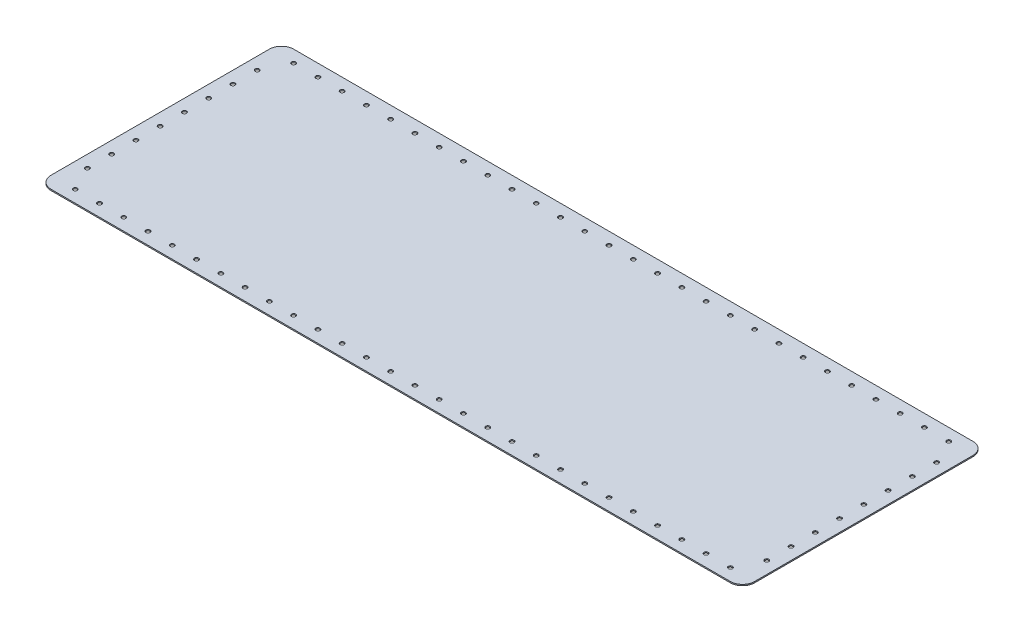
from build123d import *

# Parameters (mm, degrees)
SKETCH1_W                      = 580
SKETCH1_H                      = 200
BOSS_EXTRUDE1_DEPTH            = 1
FILLET1_R                      = 10
M3_CLEARANCE_HOLE1_AT_2_COUNT  = 2
M3_CLEARANCE_HOLE1_AT_2_PITCH  = 22.360679775
M3_CLEARANCE_HOLE1_AT_3_COUNT  = 2
M3_CLEARANCE_HOLE1_AT_3_PITCH  = 36.055512755
M3_CLEARANCE_HOLE1_AT_4_COUNT  = 2
M3_CLEARANCE_HOLE1_AT_4_PITCH  = 53.851648071
M3_CLEARANCE_HOLE1_AT_5_COUNT  = 2
M3_CLEARANCE_HOLE1_AT_5_PITCH  = 72.801098893
M3_CLEARANCE_HOLE1_AT_6_COUNT  = 2
M3_CLEARANCE_HOLE1_AT_6_PITCH  = 92.195444573
M3_CLEARANCE_HOLE1_AT_7_COUNT  = 2
M3_CLEARANCE_HOLE1_AT_7_PITCH  = 111.803398875
M3_CLEARANCE_HOLE1_AT_8_COUNT  = 2
M3_CLEARANCE_HOLE1_AT_8_PITCH  = 131.52946438
M3_CLEARANCE_HOLE1_AT_9_COUNT  = 2
M3_CLEARANCE_HOLE1_AT_9_PITCH  = 151.327459504
M3_CLEARANCE_HOLE1_AT_10_COUNT = 2
M3_CLEARANCE_HOLE1_AT_10_PITCH = 171.172427686
M3_CLEARANCE_HOLE1_AT_11_COUNT = 2
M3_CLEARANCE_HOLE1_AT_11_PITCH = 191.049731745
M3_CLEARANCE_HOLE1_AT_12_COUNT = 2
M3_CLEARANCE_HOLE1_AT_12_PITCH = 210.950231097
M3_CLEARANCE_HOLE1_AT_13_COUNT = 2
M3_CLEARANCE_HOLE1_AT_13_PITCH = 230.867927612
M3_CLEARANCE_HOLE1_AT_14_COUNT = 2
M3_CLEARANCE_HOLE1_AT_14_PITCH = 250.79872408
M3_CLEARANCE_HOLE1_AT_15_COUNT = 2
M3_CLEARANCE_HOLE1_AT_15_PITCH = 270.739727414
M3_CLEARANCE_HOLE1_AT_16_COUNT = 2
M3_CLEARANCE_HOLE1_AT_16_PITCH = 290.688837075
M3_CLEARANCE_HOLE1_AT_17_COUNT = 2
M3_CLEARANCE_HOLE1_AT_17_PITCH = 310.64449134
M3_CLEARANCE_HOLE1_AT_18_COUNT = 2
M3_CLEARANCE_HOLE1_AT_18_PITCH = 330.605505096
M3_CLEARANCE_HOLE1_AT_19_COUNT = 2
M3_CLEARANCE_HOLE1_AT_19_PITCH = 350.570962859
M3_CLEARANCE_HOLE1_AT_20_COUNT = 2
M3_CLEARANCE_HOLE1_AT_20_PITCH = 370.540146273
M3_CLEARANCE_HOLE1_AT_21_COUNT = 2
M3_CLEARANCE_HOLE1_AT_21_PITCH = 390.512483795
M3_CLEARANCE_HOLE1_AT_22_COUNT = 2
M3_CLEARANCE_HOLE1_AT_22_PITCH = 410.487515035
M3_CLEARANCE_HOLE1_AT_23_COUNT = 2
M3_CLEARANCE_HOLE1_AT_23_PITCH = 430.464865001
M3_CLEARANCE_HOLE1_AT_24_COUNT = 2
M3_CLEARANCE_HOLE1_AT_24_PITCH = 450.444225182
M3_CLEARANCE_HOLE1_AT_25_COUNT = 2
M3_CLEARANCE_HOLE1_AT_25_PITCH = 470.425339454
M3_CLEARANCE_HOLE1_AT_26_COUNT = 2
M3_CLEARANCE_HOLE1_AT_26_PITCH = 490.40799341
M3_CLEARANCE_HOLE1_AT_27_COUNT = 2
M3_CLEARANCE_HOLE1_AT_27_PITCH = 510.392006207
M3_CLEARANCE_HOLE1_AT_28_COUNT = 2
M3_CLEARANCE_HOLE1_AT_28_PITCH = 530.377224247
M3_CLEARANCE_HOLE1_AT_29_COUNT = 2
M3_CLEARANCE_HOLE1_AT_29_PITCH = 550.363516233
M3_CLEARANCE_HOLE1_AT_30_COUNT = 2
M3_CLEARANCE_HOLE1_AT_30_PITCH = 19.996953903
M3_CLEARANCE_HOLE1_AT_31_COUNT = 2
M3_CLEARANCE_HOLE1_AT_31_PITCH = 39.993907806
M3_CLEARANCE_HOLE1_AT_32_COUNT = 2
M3_CLEARANCE_HOLE1_AT_32_PITCH = 59.990861709
M3_CLEARANCE_HOLE1_AT_33_COUNT = 2
M3_CLEARANCE_HOLE1_AT_33_PITCH = 79.987815613
M3_CLEARANCE_HOLE1_AT_34_COUNT = 2
M3_CLEARANCE_HOLE1_AT_34_PITCH = 99.984769516
M3_CLEARANCE_HOLE1_AT_35_COUNT = 2
M3_CLEARANCE_HOLE1_AT_35_PITCH = 119.981723419
M3_CLEARANCE_HOLE1_AT_36_COUNT = 2
M3_CLEARANCE_HOLE1_AT_36_PITCH = 139.978677322
M3_CLEARANCE_HOLE1_AT_37_COUNT = 2
M3_CLEARANCE_HOLE1_AT_37_PITCH = 160.312195419
M3_CLEARANCE_HOLE1_AT_38_COUNT = 2
M3_CLEARANCE_HOLE1_AT_38_PITCH = 162.788205961
M3_CLEARANCE_HOLE1_AT_39_COUNT = 2
M3_CLEARANCE_HOLE1_AT_39_PITCH = 167.630546142
M3_CLEARANCE_HOLE1_AT_40_COUNT = 2
M3_CLEARANCE_HOLE1_AT_40_PITCH = 174.642491966
M3_CLEARANCE_HOLE1_AT_41_COUNT = 2
M3_CLEARANCE_HOLE1_AT_41_PITCH = 183.575597507
M3_CLEARANCE_HOLE1_AT_42_COUNT = 2
M3_CLEARANCE_HOLE1_AT_42_PITCH = 194.164878389
M3_CLEARANCE_HOLE1_AT_43_COUNT = 2
M3_CLEARANCE_HOLE1_AT_43_PITCH = 206.155281281
M3_CLEARANCE_HOLE1_AT_44_COUNT = 2
M3_CLEARANCE_HOLE1_AT_44_PITCH = 219.317121995
M3_CLEARANCE_HOLE1_AT_45_COUNT = 2
M3_CLEARANCE_HOLE1_AT_45_PITCH = 233.452350599
M3_CLEARANCE_HOLE1_AT_46_COUNT = 2
M3_CLEARANCE_HOLE1_AT_46_PITCH = 248.394846967
M3_CLEARANCE_HOLE1_AT_47_COUNT = 2
M3_CLEARANCE_HOLE1_AT_47_PITCH = 264.007575649
M3_CLEARANCE_HOLE1_AT_48_COUNT = 2
M3_CLEARANCE_HOLE1_AT_48_PITCH = 280.178514522
M3_CLEARANCE_HOLE1_AT_49_COUNT = 2
M3_CLEARANCE_HOLE1_AT_49_PITCH = 296.816441593
M3_CLEARANCE_HOLE1_AT_50_COUNT = 2
M3_CLEARANCE_HOLE1_AT_50_PITCH = 313.84709653
M3_CLEARANCE_HOLE1_AT_51_COUNT = 2
M3_CLEARANCE_HOLE1_AT_51_PITCH = 331.209903234
M3_CLEARANCE_HOLE1_AT_52_COUNT = 2
M3_CLEARANCE_HOLE1_AT_52_PITCH = 348.85527085
M3_CLEARANCE_HOLE1_AT_53_COUNT = 2
M3_CLEARANCE_HOLE1_AT_53_PITCH = 366.742416418
M3_CLEARANCE_HOLE1_AT_54_COUNT = 2
M3_CLEARANCE_HOLE1_AT_54_PITCH = 384.837628098
M3_CLEARANCE_HOLE1_AT_55_COUNT = 2
M3_CLEARANCE_HOLE1_AT_55_PITCH = 403.112887415
M3_CLEARANCE_HOLE1_AT_56_COUNT = 2
M3_CLEARANCE_HOLE1_AT_56_PITCH = 421.544778167
M3_CLEARANCE_HOLE1_AT_57_COUNT = 2
M3_CLEARANCE_HOLE1_AT_57_PITCH = 440.113621693
M3_CLEARANCE_HOLE1_AT_58_COUNT = 2
M3_CLEARANCE_HOLE1_AT_58_PITCH = 458.802789878
M3_CLEARANCE_HOLE1_AT_59_COUNT = 2
M3_CLEARANCE_HOLE1_AT_59_PITCH = 477.59815745
M3_CLEARANCE_HOLE1_AT_60_COUNT = 2
M3_CLEARANCE_HOLE1_AT_60_PITCH = 496.487663492
M3_CLEARANCE_HOLE1_AT_61_COUNT = 2
M3_CLEARANCE_HOLE1_AT_61_PITCH = 515.460958754
M3_CLEARANCE_HOLE1_AT_62_COUNT = 2
M3_CLEARANCE_HOLE1_AT_62_PITCH = 534.509120596
M3_CLEARANCE_HOLE1_AT_63_COUNT = 2
M3_CLEARANCE_HOLE1_AT_63_PITCH = 553.624421427
M3_CLEARANCE_HOLE1_AT_64_COUNT = 2
M3_CLEARANCE_HOLE1_AT_64_PITCH = 572.800139665
M3_CLEARANCE_HOLE1_AT_65_COUNT = 2
M3_CLEARANCE_HOLE1_AT_65_PITCH = 560
M3_CLEARANCE_HOLE1_AT_66_COUNT = 2
M3_CLEARANCE_HOLE1_AT_66_PITCH = 560.356920333
M3_CLEARANCE_HOLE1_AT_67_COUNT = 2
M3_CLEARANCE_HOLE1_AT_67_PITCH = 561.426319887
M3_CLEARANCE_HOLE1_AT_68_COUNT = 2
M3_CLEARANCE_HOLE1_AT_68_PITCH = 563.204140156
M3_CLEARANCE_HOLE1_AT_69_COUNT = 2
M3_CLEARANCE_HOLE1_AT_69_PITCH = 565.683701945
M3_CLEARANCE_HOLE1_AT_70_COUNT = 2
M3_CLEARANCE_HOLE1_AT_70_PITCH = 568.855828954
M3_CLEARANCE_HOLE1_AT_71_COUNT = 2
M3_CLEARANCE_HOLE1_AT_71_PITCH = 572.709013334
M3_CLEARANCE_HOLE1_AT_72_COUNT = 2
M3_CLEARANCE_HOLE1_AT_72_PITCH = 577.229616448


with BuildPart() as part:
    # Sketch1 → Boss-Extrude1 (new body)
    with BuildSketch(Plane(origin=(0, 0, 0), x_dir=(1, 0, 0), z_dir=(0, 1, 0))):
        Rectangle(SKETCH1_W, SKETCH1_H)
    extrude(amount=BOSS_EXTRUDE1_DEPTH)

    # Fillet1
    fillet1_edges = [part.edges().sort_by_distance(p)[0] for p in [
        (290, 0.5, 100),
        (-290, 0.5, 100),
        (-290, 0.5, -100),
        (290, 0.5, -100),
    ]]
    fillet(fillet1_edges, radius=FILLET1_R)

    # Sketch3 → M3 Clearance Hole1 (revolve, cut)
    with BuildSketch(Plane(origin=(280, 1, -70), x_dir=(0, 0, 1), z_dir=(1, 0, 0))):
        Polygon((0, 0), (0, 1), (1.7, 1), (1.7, 0.025), (1.725, 0), align=None)
    m3_clearance_hole1 = revolve(axis=Axis((280, 7.35, -70), (0, -1, 0)), mode=Mode.SUBTRACT)

    # M3 Clearance Hole1 at 2: M3 Clearance Hole1 ×2
    with Locations(*[Vector(-0.447213595, 0, -0.894427191) * (i * M3_CLEARANCE_HOLE1_AT_2_PITCH) for i in range(1, M3_CLEARANCE_HOLE1_AT_2_COUNT)]):
        add(m3_clearance_hole1, mode=Mode.SUBTRACT)

    # M3 Clearance Hole1 at 3: M3 Clearance Hole1 ×2
    with Locations(*[Vector(-0.832050294, 0, -0.554700196) * (i * M3_CLEARANCE_HOLE1_AT_3_PITCH) for i in range(1, M3_CLEARANCE_HOLE1_AT_3_COUNT)]):
        add(m3_clearance_hole1, mode=Mode.SUBTRACT)

    # M3 Clearance Hole1 at 4: M3 Clearance Hole1 ×2
    with Locations(*[Vector(-0.928476691, 0, -0.371390676) * (i * M3_CLEARANCE_HOLE1_AT_4_PITCH) for i in range(1, M3_CLEARANCE_HOLE1_AT_4_COUNT)]):
        add(m3_clearance_hole1, mode=Mode.SUBTRACT)

    # M3 Clearance Hole1 at 5: M3 Clearance Hole1 ×2
    with Locations(*[Vector(-0.961523948, 0, -0.274721128) * (i * M3_CLEARANCE_HOLE1_AT_5_PITCH) for i in range(1, M3_CLEARANCE_HOLE1_AT_5_COUNT)]):
        add(m3_clearance_hole1, mode=Mode.SUBTRACT)

    # M3 Clearance Hole1 at 6: M3 Clearance Hole1 ×2
    with Locations(*[Vector(-0.97618706, 0, -0.216930458) * (i * M3_CLEARANCE_HOLE1_AT_6_PITCH) for i in range(1, M3_CLEARANCE_HOLE1_AT_6_COUNT)]):
        add(m3_clearance_hole1, mode=Mode.SUBTRACT)

    # M3 Clearance Hole1 at 7: M3 Clearance Hole1 ×2
    with Locations(*[Vector(-0.98386991, 0, -0.178885438) * (i * M3_CLEARANCE_HOLE1_AT_7_PITCH) for i in range(1, M3_CLEARANCE_HOLE1_AT_7_COUNT)]):
        add(m3_clearance_hole1, mode=Mode.SUBTRACT)

    # M3 Clearance Hole1 at 8: M3 Clearance Hole1 ×2
    with Locations(*[Vector(-0.988371698, 0, -0.152057184) * (i * M3_CLEARANCE_HOLE1_AT_8_PITCH) for i in range(1, M3_CLEARANCE_HOLE1_AT_8_COUNT)]):
        add(m3_clearance_hole1, mode=Mode.SUBTRACT)

    # M3 Clearance Hole1 at 9: M3 Clearance Hole1 ×2
    with Locations(*[Vector(-0.991227901, 0, -0.13216372) * (i * M3_CLEARANCE_HOLE1_AT_9_PITCH) for i in range(1, M3_CLEARANCE_HOLE1_AT_9_COUNT)]):
        add(m3_clearance_hole1, mode=Mode.SUBTRACT)

    # M3 Clearance Hole1 at 10: M3 Clearance Hole1 ×2
    with Locations(*[Vector(-0.993150604, 0, -0.116841248) * (i * M3_CLEARANCE_HOLE1_AT_10_PITCH) for i in range(1, M3_CLEARANCE_HOLE1_AT_10_COUNT)]):
        add(m3_clearance_hole1, mode=Mode.SUBTRACT)

    # M3 Clearance Hole1 at 11: M3 Clearance Hole1 ×2
    with Locations(*[Vector(-0.994505453, 0, -0.104684785) * (i * M3_CLEARANCE_HOLE1_AT_11_PITCH) for i in range(1, M3_CLEARANCE_HOLE1_AT_11_COUNT)]):
        add(m3_clearance_hole1, mode=Mode.SUBTRACT)

    # M3 Clearance Hole1 at 12: M3 Clearance Hole1 ×2
    with Locations(*[Vector(-0.995495473, 0, -0.094809093) * (i * M3_CLEARANCE_HOLE1_AT_12_PITCH) for i in range(1, M3_CLEARANCE_HOLE1_AT_12_COUNT)]):
        add(m3_clearance_hole1, mode=Mode.SUBTRACT)

    # M3 Clearance Hole1 at 13: M3 Clearance Hole1 ×2
    with Locations(*[Vector(-0.996240588, 0, -0.086629616) * (i * M3_CLEARANCE_HOLE1_AT_13_PITCH) for i in range(1, M3_CLEARANCE_HOLE1_AT_13_COUNT)]):
        add(m3_clearance_hole1, mode=Mode.SUBTRACT)

    # M3 Clearance Hole1 at 14: M3 Clearance Hole1 ×2
    with Locations(*[Vector(-0.996815279, 0, -0.079745222) * (i * M3_CLEARANCE_HOLE1_AT_14_PITCH) for i in range(1, M3_CLEARANCE_HOLE1_AT_14_COUNT)]):
        add(m3_clearance_hole1, mode=Mode.SUBTRACT)

    # M3 Clearance Hole1 at 15: M3 Clearance Hole1 ×2
    with Locations(*[Vector(-0.997267754, 0, -0.073871686) * (i * M3_CLEARANCE_HOLE1_AT_15_PITCH) for i in range(1, M3_CLEARANCE_HOLE1_AT_15_COUNT)]):
        add(m3_clearance_hole1, mode=Mode.SUBTRACT)

    # M3 Clearance Hole1 at 16: M3 Clearance Hole1 ×2
    with Locations(*[Vector(-0.997630328, 0, -0.068802092) * (i * M3_CLEARANCE_HOLE1_AT_16_PITCH) for i in range(1, M3_CLEARANCE_HOLE1_AT_16_COUNT)]):
        add(m3_clearance_hole1, mode=Mode.SUBTRACT)

    # M3 Clearance Hole1 at 17: M3 Clearance Hole1 ×2
    with Locations(*[Vector(-0.997925309, 0, -0.064382278) * (i * M3_CLEARANCE_HOLE1_AT_17_PITCH) for i in range(1, M3_CLEARANCE_HOLE1_AT_17_COUNT)]):
        add(m3_clearance_hole1, mode=Mode.SUBTRACT)

    # M3 Clearance Hole1 at 18: M3 Clearance Hole1 ×2
    with Locations(*[Vector(-0.998168497, 0, -0.06049506) * (i * M3_CLEARANCE_HOLE1_AT_18_PITCH) for i in range(1, M3_CLEARANCE_HOLE1_AT_18_COUNT)]):
        add(m3_clearance_hole1, mode=Mode.SUBTRACT)

    # M3 Clearance Hole1 at 19: M3 Clearance Hole1 ×2
    with Locations(*[Vector(-0.998371334, 0, -0.057049791) * (i * M3_CLEARANCE_HOLE1_AT_19_PITCH) for i in range(1, M3_CLEARANCE_HOLE1_AT_19_COUNT)]):
        add(m3_clearance_hole1, mode=Mode.SUBTRACT)

    # M3 Clearance Hole1 at 20: M3 Clearance Hole1 ×2
    with Locations(*[Vector(-0.998542273, 0, -0.053975258) * (i * M3_CLEARANCE_HOLE1_AT_20_PITCH) for i in range(1, M3_CLEARANCE_HOLE1_AT_20_COUNT)]):
        add(m3_clearance_hole1, mode=Mode.SUBTRACT)

    # M3 Clearance Hole1 at 21: M3 Clearance Hole1 ×2
    with Locations(*[Vector(-0.998687663, 0, -0.051214752) * (i * M3_CLEARANCE_HOLE1_AT_21_PITCH) for i in range(1, M3_CLEARANCE_HOLE1_AT_21_COUNT)]):
        add(m3_clearance_hole1, mode=Mode.SUBTRACT)

    # M3 Clearance Hole1 at 22: M3 Clearance Hole1 ×2
    with Locations(*[Vector(-0.998812351, 0, -0.048722554) * (i * M3_CLEARANCE_HOLE1_AT_22_PITCH) for i in range(1, M3_CLEARANCE_HOLE1_AT_22_COUNT)]):
        add(m3_clearance_hole1, mode=Mode.SUBTRACT)

    # M3 Clearance Hole1 at 23: M3 Clearance Hole1 ×2
    with Locations(*[Vector(-0.998920086, 0, -0.046461399) * (i * M3_CLEARANCE_HOLE1_AT_23_PITCH) for i in range(1, M3_CLEARANCE_HOLE1_AT_23_COUNT)]):
        add(m3_clearance_hole1, mode=Mode.SUBTRACT)

    # M3 Clearance Hole1 at 24: M3 Clearance Hole1 ×2
    with Locations(*[Vector(-0.999013806, 0, -0.044400614) * (i * M3_CLEARANCE_HOLE1_AT_24_PITCH) for i in range(1, M3_CLEARANCE_HOLE1_AT_24_COUNT)]):
        add(m3_clearance_hole1, mode=Mode.SUBTRACT)

    # M3 Clearance Hole1 at 25: M3 Clearance Hole1 ×2
    with Locations(*[Vector(-0.999095841, 0, -0.042514717) * (i * M3_CLEARANCE_HOLE1_AT_25_PITCH) for i in range(1, M3_CLEARANCE_HOLE1_AT_25_COUNT)]):
        add(m3_clearance_hole1, mode=Mode.SUBTRACT)

    # M3 Clearance Hole1 at 26: M3 Clearance Hole1 ×2
    with Locations(*[Vector(-0.999168053, 0, -0.04078237) * (i * M3_CLEARANCE_HOLE1_AT_26_PITCH) for i in range(1, M3_CLEARANCE_HOLE1_AT_26_COUNT)]):
        add(m3_clearance_hole1, mode=Mode.SUBTRACT)

    # M3 Clearance Hole1 at 27: M3 Clearance Hole1 ×2
    with Locations(*[Vector(-0.999231951, 0, -0.039185567) * (i * M3_CLEARANCE_HOLE1_AT_27_PITCH) for i in range(1, M3_CLEARANCE_HOLE1_AT_27_COUNT)]):
        add(m3_clearance_hole1, mode=Mode.SUBTRACT)

    # M3 Clearance Hole1 at 28: M3 Clearance Hole1 ×2
    with Locations(*[Vector(-0.999288762, 0, -0.03770901) * (i * M3_CLEARANCE_HOLE1_AT_28_PITCH) for i in range(1, M3_CLEARANCE_HOLE1_AT_28_COUNT)]):
        add(m3_clearance_hole1, mode=Mode.SUBTRACT)

    # M3 Clearance Hole1 at 29: M3 Clearance Hole1 ×2
    with Locations(*[Vector(-0.999339498, 0, -0.036339618) * (i * M3_CLEARANCE_HOLE1_AT_29_PITCH) for i in range(1, M3_CLEARANCE_HOLE1_AT_29_COUNT)]):
        add(m3_clearance_hole1, mode=Mode.SUBTRACT)

    # M3 Clearance Hole1 at 30: M3 Clearance Hole1 ×2
    with Locations(*[(0, 0, i * M3_CLEARANCE_HOLE1_AT_30_PITCH) for i in range(1, M3_CLEARANCE_HOLE1_AT_30_COUNT)]):
        add(m3_clearance_hole1, mode=Mode.SUBTRACT)

    # M3 Clearance Hole1 at 31: M3 Clearance Hole1 ×2
    with Locations(*[(0, 0, i * M3_CLEARANCE_HOLE1_AT_31_PITCH) for i in range(1, M3_CLEARANCE_HOLE1_AT_31_COUNT)]):
        add(m3_clearance_hole1, mode=Mode.SUBTRACT)

    # M3 Clearance Hole1 at 32: M3 Clearance Hole1 ×2
    with Locations(*[(0, 0, i * M3_CLEARANCE_HOLE1_AT_32_PITCH) for i in range(1, M3_CLEARANCE_HOLE1_AT_32_COUNT)]):
        add(m3_clearance_hole1, mode=Mode.SUBTRACT)

    # M3 Clearance Hole1 at 33: M3 Clearance Hole1 ×2
    with Locations(*[(0, 0, i * M3_CLEARANCE_HOLE1_AT_33_PITCH) for i in range(1, M3_CLEARANCE_HOLE1_AT_33_COUNT)]):
        add(m3_clearance_hole1, mode=Mode.SUBTRACT)

    # M3 Clearance Hole1 at 34: M3 Clearance Hole1 ×2
    with Locations(*[(0, 0, i * M3_CLEARANCE_HOLE1_AT_34_PITCH) for i in range(1, M3_CLEARANCE_HOLE1_AT_34_COUNT)]):
        add(m3_clearance_hole1, mode=Mode.SUBTRACT)

    # M3 Clearance Hole1 at 35: M3 Clearance Hole1 ×2
    with Locations(*[(0, 0, i * M3_CLEARANCE_HOLE1_AT_35_PITCH) for i in range(1, M3_CLEARANCE_HOLE1_AT_35_COUNT)]):
        add(m3_clearance_hole1, mode=Mode.SUBTRACT)

    # M3 Clearance Hole1 at 36: M3 Clearance Hole1 ×2
    with Locations(*[(0, 0, i * M3_CLEARANCE_HOLE1_AT_36_PITCH) for i in range(1, M3_CLEARANCE_HOLE1_AT_36_COUNT)]):
        add(m3_clearance_hole1, mode=Mode.SUBTRACT)

    # M3 Clearance Hole1 at 37: M3 Clearance Hole1 ×2
    with Locations(*[Vector(-0.062378286, 0, 0.998052578) * (i * M3_CLEARANCE_HOLE1_AT_37_PITCH) for i in range(1, M3_CLEARANCE_HOLE1_AT_37_COUNT)]):
        add(m3_clearance_hole1, mode=Mode.SUBTRACT)

    # M3 Clearance Hole1 at 38: M3 Clearance Hole1 ×2
    with Locations(*[Vector(-0.184288535, 0, 0.982872187) * (i * M3_CLEARANCE_HOLE1_AT_38_PITCH) for i in range(1, M3_CLEARANCE_HOLE1_AT_38_COUNT)]):
        add(m3_clearance_hole1, mode=Mode.SUBTRACT)

    # M3 Clearance Hole1 at 39: M3 Clearance Hole1 ×2
    with Locations(*[Vector(-0.298274993, 0, 0.954479978) * (i * M3_CLEARANCE_HOLE1_AT_39_PITCH) for i in range(1, M3_CLEARANCE_HOLE1_AT_39_COUNT)]):
        add(m3_clearance_hole1, mode=Mode.SUBTRACT)

    # M3 Clearance Hole1 at 40: M3 Clearance Hole1 ×2
    with Locations(*[Vector(-0.400818834, 0, 0.916157335) * (i * M3_CLEARANCE_HOLE1_AT_40_PITCH) for i in range(1, M3_CLEARANCE_HOLE1_AT_40_COUNT)]):
        add(m3_clearance_hole1, mode=Mode.SUBTRACT)

    # M3 Clearance Hole1 at 41: M3 Clearance Hole1 ×2
    with Locations(*[Vector(-0.49026124, 0, 0.871575537) * (i * M3_CLEARANCE_HOLE1_AT_41_PITCH) for i in range(1, M3_CLEARANCE_HOLE1_AT_41_COUNT)]):
        add(m3_clearance_hole1, mode=Mode.SUBTRACT)

    # M3 Clearance Hole1 at 42: M3 Clearance Hole1 ×2
    with Locations(*[Vector(-0.566528823, 0, 0.824041924) * (i * M3_CLEARANCE_HOLE1_AT_42_PITCH) for i in range(1, M3_CLEARANCE_HOLE1_AT_42_COUNT)]):
        add(m3_clearance_hole1, mode=Mode.SUBTRACT)

    # M3 Clearance Hole1 at 43: M3 Clearance Hole1 ×2
    with Locations(*[Vector(-0.630592625, 0, 0.776114) * (i * M3_CLEARANCE_HOLE1_AT_43_PITCH) for i in range(1, M3_CLEARANCE_HOLE1_AT_43_COUNT)]):
        add(m3_clearance_hole1, mode=Mode.SUBTRACT)

    # M3 Clearance Hole1 at 44: M3 Clearance Hole1 ×2
    with Locations(*[Vector(-0.683941129, 0, 0.729537204) * (i * M3_CLEARANCE_HOLE1_AT_44_PITCH) for i in range(1, M3_CLEARANCE_HOLE1_AT_44_COUNT)]):
        add(m3_clearance_hole1, mode=Mode.SUBTRACT)

    # M3 Clearance Hole1 at 45: M3 Clearance Hole1 ×2
    with Locations(*[Vector(-0.728199993, 0, 0.685364699) * (i * M3_CLEARANCE_HOLE1_AT_45_PITCH) for i in range(1, M3_CLEARANCE_HOLE1_AT_45_COUNT)]):
        add(m3_clearance_hole1, mode=Mode.SUBTRACT)

    # M3 Clearance Hole1 at 46: M3 Clearance Hole1 ×2
    with Locations(*[Vector(-0.764911198, 0, 0.644135746) * (i * M3_CLEARANCE_HOLE1_AT_46_PITCH) for i in range(1, M3_CLEARANCE_HOLE1_AT_46_COUNT)]):
        add(m3_clearance_hole1, mode=Mode.SUBTRACT)

    # M3 Clearance Hole1 at 47: M3 Clearance Hole1 ×2
    with Locations(*[Vector(-0.79543172, 0, 0.606043215) * (i * M3_CLEARANCE_HOLE1_AT_47_PITCH) for i in range(1, M3_CLEARANCE_HOLE1_AT_47_COUNT)]):
        add(m3_clearance_hole1, mode=Mode.SUBTRACT)

    # M3 Clearance Hole1 at 48: M3 Clearance Hole1 ×2
    with Locations(*[Vector(-0.820905202, 0, 0.571064488) * (i * M3_CLEARANCE_HOLE1_AT_48_PITCH) for i in range(1, M3_CLEARANCE_HOLE1_AT_48_COUNT)]):
        add(m3_clearance_hole1, mode=Mode.SUBTRACT)

    # M3 Clearance Hole1 at 49: M3 Clearance Hole1 ×2
    with Locations(*[Vector(-0.842271401, 0, 0.539053696) * (i * M3_CLEARANCE_HOLE1_AT_49_PITCH) for i in range(1, M3_CLEARANCE_HOLE1_AT_49_COUNT)]):
        add(m3_clearance_hole1, mode=Mode.SUBTRACT)

    # M3 Clearance Hole1 at 50: M3 Clearance Hole1 ×2
    with Locations(*[Vector(-0.860291534, 0, 0.50980239) * (i * M3_CLEARANCE_HOLE1_AT_50_PITCH) for i in range(1, M3_CLEARANCE_HOLE1_AT_50_COUNT)]):
        add(m3_clearance_hole1, mode=Mode.SUBTRACT)

    # M3 Clearance Hole1 at 51: M3 Clearance Hole1 ×2
    with Locations(*[Vector(-0.875577684, 0, 0.483077343) * (i * M3_CLEARANCE_HOLE1_AT_51_PITCH) for i in range(1, M3_CLEARANCE_HOLE1_AT_51_COUNT)]):
        add(m3_clearance_hole1, mode=Mode.SUBTRACT)

    # M3 Clearance Hole1 at 52: M3 Clearance Hole1 ×2
    with Locations(*[Vector(-0.888620657, 0, 0.45864292) * (i * M3_CLEARANCE_HOLE1_AT_52_PITCH) for i in range(1, M3_CLEARANCE_HOLE1_AT_52_COUNT)]):
        add(m3_clearance_hole1, mode=Mode.SUBTRACT)

    # M3 Clearance Hole1 at 53: M3 Clearance Hole1 ×2
    with Locations(*[Vector(-0.899814107, 0, 0.436273507) * (i * M3_CLEARANCE_HOLE1_AT_53_PITCH) for i in range(1, M3_CLEARANCE_HOLE1_AT_53_COUNT)]):
        add(m3_clearance_hole1, mode=Mode.SUBTRACT)

    # M3 Clearance Hole1 at 54: M3 Clearance Hole1 ×2
    with Locations(*[Vector(-0.909474476, 0, 0.41575976) * (i * M3_CLEARANCE_HOLE1_AT_54_PITCH) for i in range(1, M3_CLEARANCE_HOLE1_AT_54_COUNT)]):
        add(m3_clearance_hole1, mode=Mode.SUBTRACT)

    # M3 Clearance Hole1 at 55: M3 Clearance Hole1 ×2
    with Locations(*[Vector(-0.917857036, 0, 0.396911151) * (i * M3_CLEARANCE_HOLE1_AT_55_PITCH) for i in range(1, M3_CLEARANCE_HOLE1_AT_55_COUNT)]):
        add(m3_clearance_hole1, mode=Mode.SUBTRACT)

    # M3 Clearance Hole1 at 56: M3 Clearance Hole1 ×2
    with Locations(*[Vector(-0.925168618, 0, 0.379556356) * (i * M3_CLEARANCE_HOLE1_AT_56_PITCH) for i in range(1, M3_CLEARANCE_HOLE1_AT_56_COUNT)]):
        add(m3_clearance_hole1, mode=Mode.SUBTRACT)

    # M3 Clearance Hole1 at 57: M3 Clearance Hole1 ×2
    with Locations(*[Vector(-0.931577619, 0, 0.363542486) * (i * M3_CLEARANCE_HOLE1_AT_57_PITCH) for i in range(1, M3_CLEARANCE_HOLE1_AT_57_COUNT)]):
        add(m3_clearance_hole1, mode=Mode.SUBTRACT)

    # M3 Clearance Hole1 at 58: M3 Clearance Hole1 ×2
    with Locations(*[Vector(-0.937221851, 0, 0.348733712) * (i * M3_CLEARANCE_HOLE1_AT_58_PITCH) for i in range(1, M3_CLEARANCE_HOLE1_AT_58_COUNT)]):
        add(m3_clearance_hole1, mode=Mode.SUBTRACT)

    # M3 Clearance Hole1 at 59: M3 Clearance Hole1 ×2
    with Locations(*[Vector(-0.94221469, 0, 0.335009668) * (i * M3_CLEARANCE_HOLE1_AT_59_PITCH) for i in range(1, M3_CLEARANCE_HOLE1_AT_59_COUNT)]):
        add(m3_clearance_hole1, mode=Mode.SUBTRACT)

    # M3 Clearance Hole1 at 60: M3 Clearance Hole1 ×2
    with Locations(*[Vector(-0.946649906, 0, 0.322263798) * (i * M3_CLEARANCE_HOLE1_AT_60_PITCH) for i in range(1, M3_CLEARANCE_HOLE1_AT_60_COUNT)]):
        add(m3_clearance_hole1, mode=Mode.SUBTRACT)

    # M3 Clearance Hole1 at 61: M3 Clearance Hole1 ×2
    with Locations(*[Vector(-0.950605456, 0, 0.310401782) * (i * M3_CLEARANCE_HOLE1_AT_61_PITCH) for i in range(1, M3_CLEARANCE_HOLE1_AT_61_COUNT)]):
        add(m3_clearance_hole1, mode=Mode.SUBTRACT)

    # M3 Clearance Hole1 at 62: M3 Clearance Hole1 ×2
    with Locations(*[Vector(-0.954146488, 0, 0.299340075) * (i * M3_CLEARANCE_HOLE1_AT_62_PITCH) for i in range(1, M3_CLEARANCE_HOLE1_AT_62_COUNT)]):
        add(m3_clearance_hole1, mode=Mode.SUBTRACT)

    # M3 Clearance Hole1 at 63: M3 Clearance Hole1 ×2
    with Locations(*[Vector(-0.957327711, 0, 0.289004592) * (i * M3_CLEARANCE_HOLE1_AT_63_PITCH) for i in range(1, M3_CLEARANCE_HOLE1_AT_63_COUNT)]):
        add(m3_clearance_hole1, mode=Mode.SUBTRACT)

    # M3 Clearance Hole1 at 64: M3 Clearance Hole1 ×2
    with Locations(*[Vector(-0.960195297, 0, 0.279329541) * (i * M3_CLEARANCE_HOLE1_AT_64_PITCH) for i in range(1, M3_CLEARANCE_HOLE1_AT_64_COUNT)]):
        add(m3_clearance_hole1, mode=Mode.SUBTRACT)

    # M3 Clearance Hole1 at 65: M3 Clearance Hole1 ×2
    with Locations(*[(-i * M3_CLEARANCE_HOLE1_AT_65_PITCH, 0, 0) for i in range(1, M3_CLEARANCE_HOLE1_AT_65_COUNT)]):
        add(m3_clearance_hole1, mode=Mode.SUBTRACT)

    # M3 Clearance Hole1 at 66: M3 Clearance Hole1 ×2
    with Locations(*[Vector(-0.999363048, 0, 0.035686101) * (i * M3_CLEARANCE_HOLE1_AT_66_PITCH) for i in range(1, M3_CLEARANCE_HOLE1_AT_66_COUNT)]):
        add(m3_clearance_hole1, mode=Mode.SUBTRACT)

    # M3 Clearance Hole1 at 67: M3 Clearance Hole1 ×2
    with Locations(*[Vector(-0.997459471, 0, 0.071236254) * (i * M3_CLEARANCE_HOLE1_AT_67_PITCH) for i in range(1, M3_CLEARANCE_HOLE1_AT_67_COUNT)]):
        add(m3_clearance_hole1, mode=Mode.SUBTRACT)

    # M3 Clearance Hole1 at 68: M3 Clearance Hole1 ×2
    with Locations(*[Vector(-0.994310873, 0, 0.106517082) * (i * M3_CLEARANCE_HOLE1_AT_68_PITCH) for i in range(1, M3_CLEARANCE_HOLE1_AT_68_COUNT)]):
        add(m3_clearance_hole1, mode=Mode.SUBTRACT)

    # M3 Clearance Hole1 at 69: M3 Clearance Hole1 ×2
    with Locations(*[Vector(-0.989952509, 0, 0.141400248) * (i * M3_CLEARANCE_HOLE1_AT_69_PITCH) for i in range(1, M3_CLEARANCE_HOLE1_AT_69_COUNT)]):
        add(m3_clearance_hole1, mode=Mode.SUBTRACT)

    # M3 Clearance Hole1 at 70: M3 Clearance Hole1 ×2
    with Locations(*[Vector(-0.984432208, 0, 0.175764692) * (i * M3_CLEARANCE_HOLE1_AT_70_PITCH) for i in range(1, M3_CLEARANCE_HOLE1_AT_70_COUNT)]):
        add(m3_clearance_hole1, mode=Mode.SUBTRACT)

    # M3 Clearance Hole1 at 71: M3 Clearance Hole1 ×2
    with Locations(*[Vector(-0.977808952, 0, 0.209498577) * (i * M3_CLEARANCE_HOLE1_AT_71_PITCH) for i in range(1, M3_CLEARANCE_HOLE1_AT_71_COUNT)]):
        add(m3_clearance_hole1, mode=Mode.SUBTRACT)

    # M3 Clearance Hole1 at 72: M3 Clearance Hole1 ×2
    with Locations(*[Vector(-0.970151191, 0, 0.242500858) * (i * M3_CLEARANCE_HOLE1_AT_72_PITCH) for i in range(1, M3_CLEARANCE_HOLE1_AT_72_COUNT)]):
        add(m3_clearance_hole1, mode=Mode.SUBTRACT)


solid = part.part
